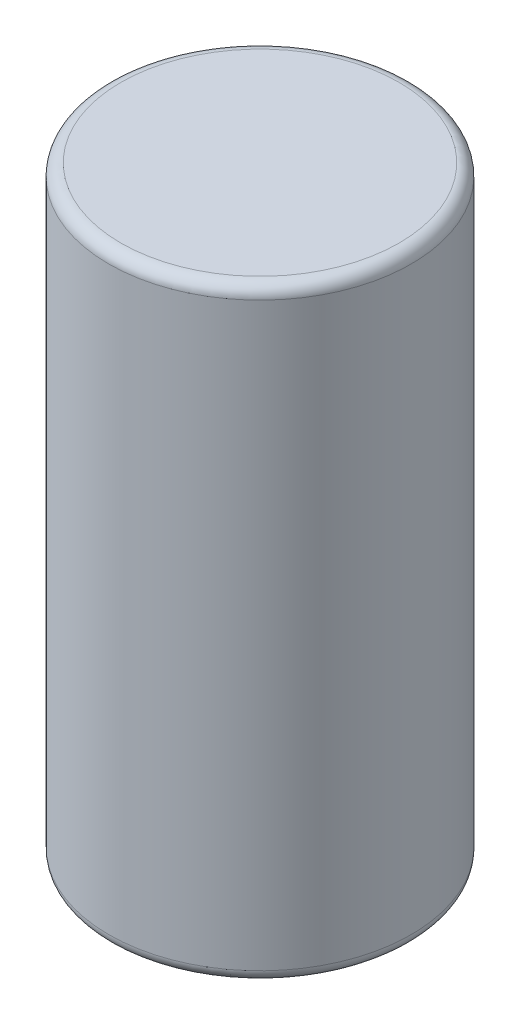
from build123d import *


with BuildPart() as part:
    # Sketch1 → Revolve1 (revolve)
    with BuildSketch(Plane.XY):
        with BuildLine():
            Line((2.921, 6.35), (0, 6.35))
            Line((0, 6.35), (0, -6.35))
            Line((0, -6.35), (2.921, -6.35))
            ThreePointArc((2.921, -6.35), (3.100605122, -6.275605122), (3.175, -6.096))
            Line((3.175, -6.096), (3.175, 6.096))
            ThreePointArc((3.175, 6.096), (3.100605122, 6.275605122), (2.921, 6.35))
        make_face()
    revolve(axis=Axis((0, 6.35, 0), (0, -1, 0)))


solid = part.part
